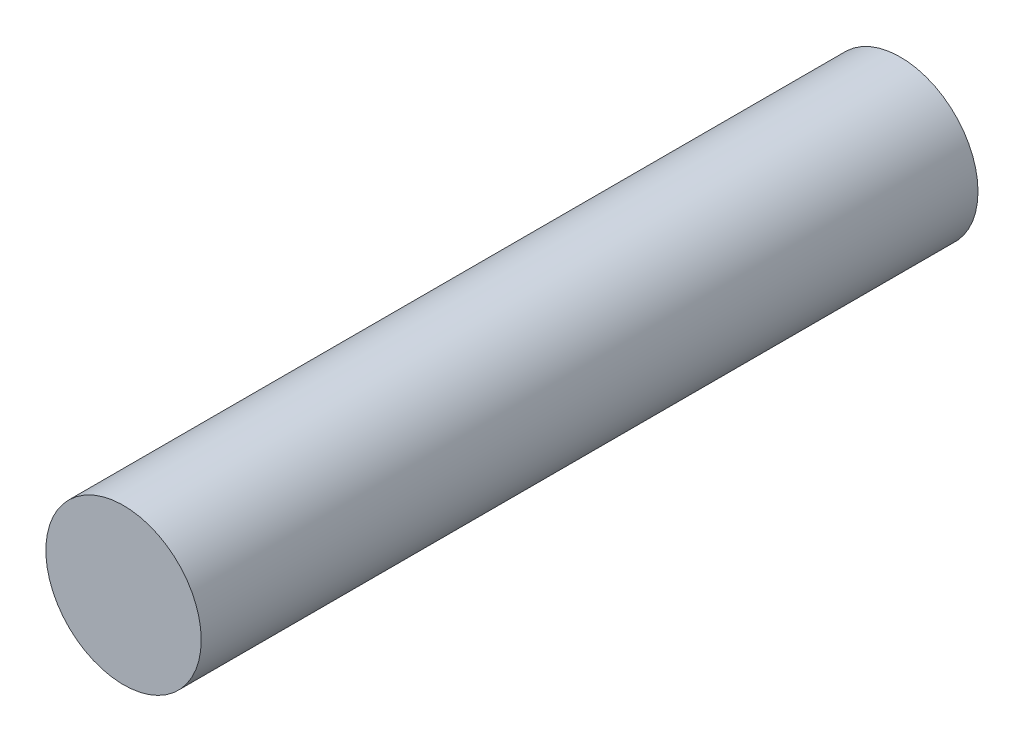
from build123d import *

# Parameters (mm, degrees)
SKETCH1_R           = 10
BOSS_EXTRUDE1_DEPTH = 100
SKETCH2_R           = 7.8
CUT_EXTRUDE1_DEPTH  = 19


with BuildPart() as part:
    # Sketch1 → Boss-Extrude1 (new body)
    with BuildSketch(Plane.XY):
        Circle(SKETCH1_R)
    extrude(amount=BOSS_EXTRUDE1_DEPTH)

    # Sketch2 → Cut-Extrude1 (cut)
    with BuildSketch(Plane(origin=(0, 0, 0), x_dir=(-1, 0, 0), z_dir=(0, 0, -1))):
        Circle(SKETCH2_R)
    extrude(amount=-CUT_EXTRUDE1_DEPTH, mode=Mode.SUBTRACT)


solid = part.part
